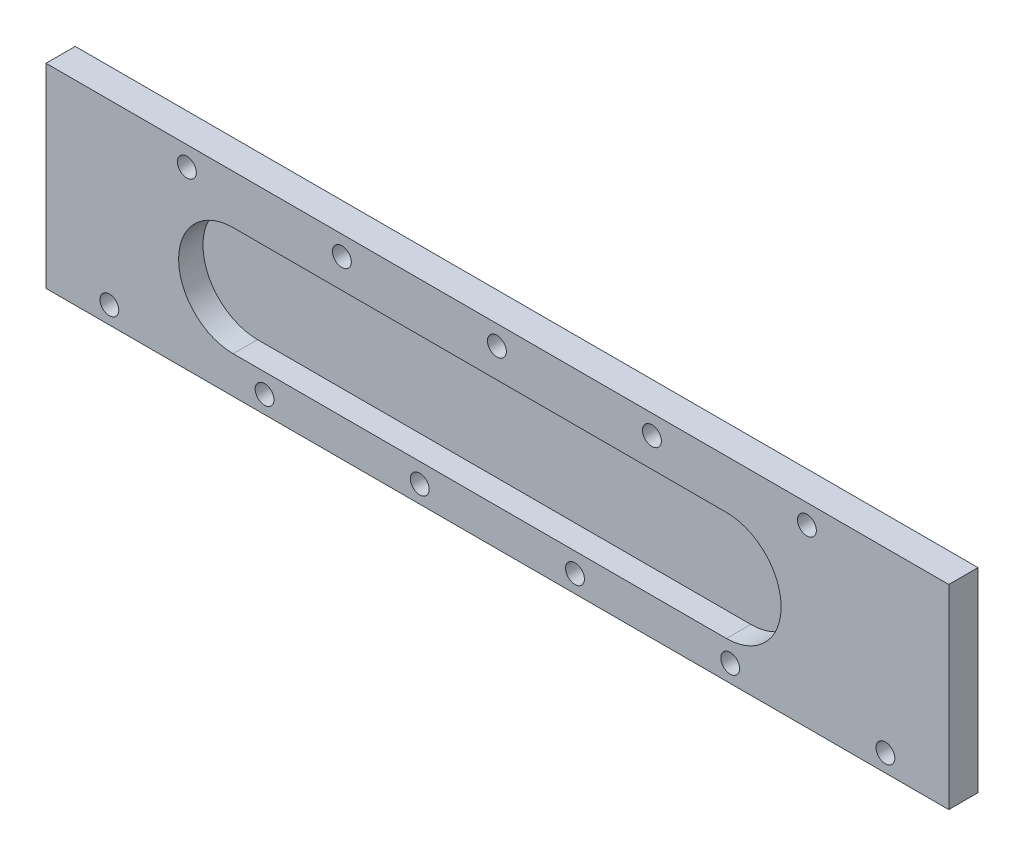
from build123d import *

# Parameters (mm, degrees)
SKETCH5_W                    = 235.204
SKETCH5_H                    = 50.8
BOSS_EXTRUDE3_DEPTH          = 7.62
CUT_EXTRUDE3_DEPTH           = 6.35
F_10_0_1935_DIAMETER_HOLE1_D = 4.9149


with BuildPart() as part:
    # Sketch5 → Boss-Extrude3 (new body)
    with BuildSketch(Plane.XY):
        with Locations((-117.602, 25.4)):
            Rectangle(SKETCH5_W, SKETCH5_H)
    extrude(amount=BOSS_EXTRUDE3_DEPTH)

    # Sketch6 → Cut-Extrude3 (cut)
    with BuildSketch(Plane.XY.offset(7.62)):
        with BuildLine():
            Line((-57.912, 9.652), (-186.436, 9.652))
            ThreePointArc((-186.436, 9.652), (-200.66, 23.876), (-186.436, 38.1))
            Line((-186.436, 38.1), (-57.912, 38.1))
            ThreePointArc((-57.912, 38.1), (-43.688, 23.876), (-57.912, 9.652))
        make_face()
    extrude(amount=-CUT_EXTRUDE3_DEPTH, mode=Mode.SUBTRACT)

    # #10 (0.1935) Diameter Hole1 (through all)
    with Locations(Plane(origin=(-198.501, 45.72, 7.62), x_dir=(1, 0, 0), z_dir=(0, 0, 1))):
        with Locations((0, 0), (40.386, 0), (80.772, 0), (121.158, 0), (161.544, 0), (-20.193, -41.171520692), (20.2438, -41.171520692), (60.6806, -41.171520692), (101.1174, -41.171520692), (141.5542, -41.171520692), (181.991, -41.171520692)):
            Hole(F_10_0_1935_DIAMETER_HOLE1_D / 2)


solid = part.part
